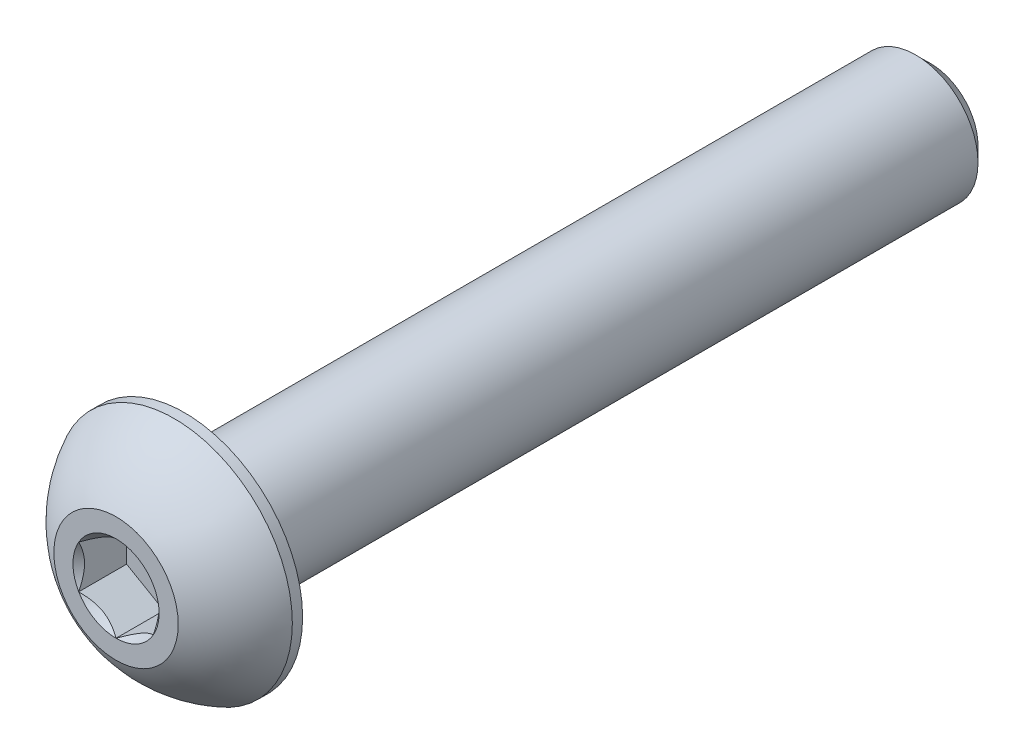
from build123d import *

# Parameters (mm, degrees)
CUT_EXTRUDE2_DEPTH = 1.925


with BuildPart() as part:
    # Sketch10 → Revolve3 (revolve)
    with BuildSketch(Plane(origin=(0, 0, 0), x_dir=(0, 0, -1), z_dir=(1, 0, 0))):
        Polygon((32.15, 2.5), (32.75, 1.9), (32.75, 0), (2.75, 0), (2.75, 2.5), align=None)
    revolve(axis=Axis((0, 0, 0), (0, 0, -1)))

    # Sketch7 → Revolve2 (revolve)
    with BuildSketch(Plane(origin=(0, 0, 0), x_dir=(0, 0, -1), z_dir=(1, 0, 0))):
        with BuildLine():
            Line((2.3375, 4.75), (2.75, 4.75))
            Line((2.75, 4.75), (2.75, 0))
            Line((2.75, 0), (0, 0))
            Line((0, 0), (0, 2.5))
            ThreePointArc((0, 2.5), (0.991875183, 3.808753282), (2.3375, 4.75))
        make_face()
    revolve(axis=Axis((0, 0, 0), (0, 0, -1)))

    # Sketch5 → Cut-Extrude2 (cut)
    with BuildSketch(Plane.XY):
        Polygon((1.5, -0.866025404), (1.5, 0.866025404), (0, 1.732050808), (-1.5, 0.866025404), (-1.5, -0.866025404), (0, -1.732050808), align=None)
    extrude(amount=-CUT_EXTRUDE2_DEPTH, mode=Mode.SUBTRACT)

    # Cut-Extrude3 cone 1 section (through the dimple's axis) → Cut-Extrude3 (revolve, cut)
    with BuildSketch(Plane(origin=(0, 0, 0), x_dir=(0, -1, 0), z_dir=(1, 0, 0))):
        Polygon((0, 0), (1.732050808, 0), (0, 1.732050808), align=None)
    revolve(axis=Axis((0, 0, 0), (0, 0, -1)), mode=Mode.SUBTRACT)


solid = part.part
